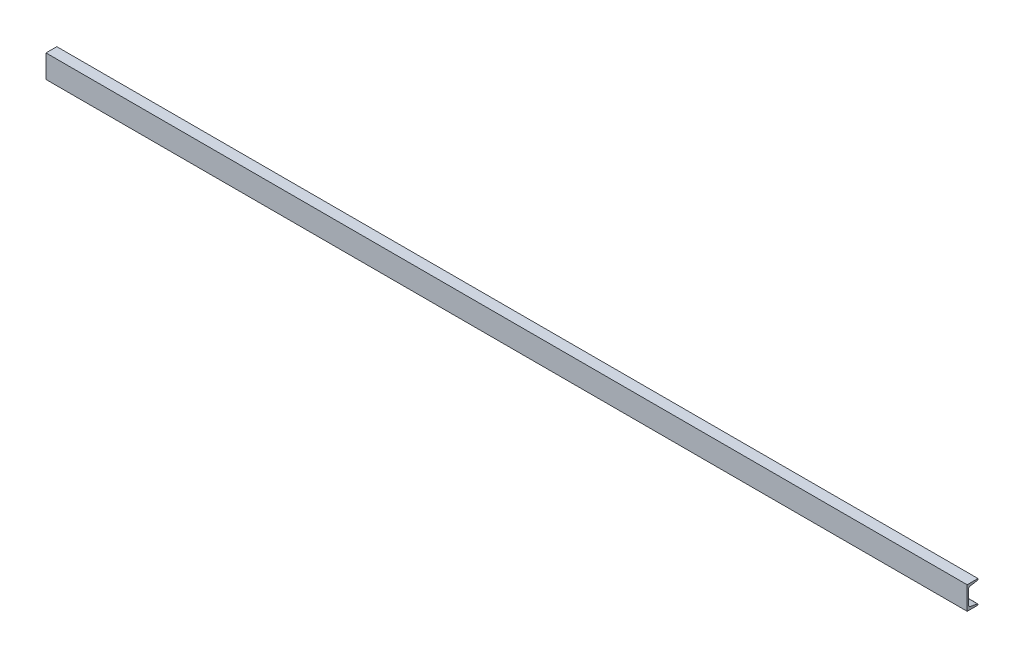
from build123d import *

# Parameters (mm, degrees)
C_CHANNEL_C3X4_1_1_DEPTH = 3048


with BuildPart() as part:
    # Sketch11 → C channel C3X4.1(1) (new body)
    with BuildSketch(Plane(origin=(0, -38.1, 0), x_dir=(0, 0, -1), z_dir=(1, 0, 0))):
        with BuildLine():
            Line((0, 0), (0, 76.2))
            Line((0, 76.2), (35.814, 76.2))
            Line((35.814, 76.2), (35.814, 74.042335136))
            ThreePointArc((35.814, 74.042335136), (35.212080466, 72.400554363), (33.691603066, 71.536899509))
            Line((33.691603066, 71.536899509), (10.048471721, 67.596090157))
            ThreePointArc((10.048471721, 67.596090157), (5.943182741, 65.264222052), (4.318, 60.831413966))
            Line((4.318, 60.831413966), (4.318, 15.368586034))
            ThreePointArc((4.318, 15.368586034), (5.943182741, 10.935777948), (10.048471721, 8.603909843))
            Line((10.048471721, 8.603909843), (33.691603066, 4.663100491))
            ThreePointArc((33.691603066, 4.663100491), (35.212080466, 3.799445637), (35.814, 2.157664864))
            Line((35.814, 2.157664864), (35.814, 0))
            Line((35.814, 0), (0, 0))
        make_face()
    extrude(amount=C_CHANNEL_C3X4_1_1_DEPTH)


solid = part.part
